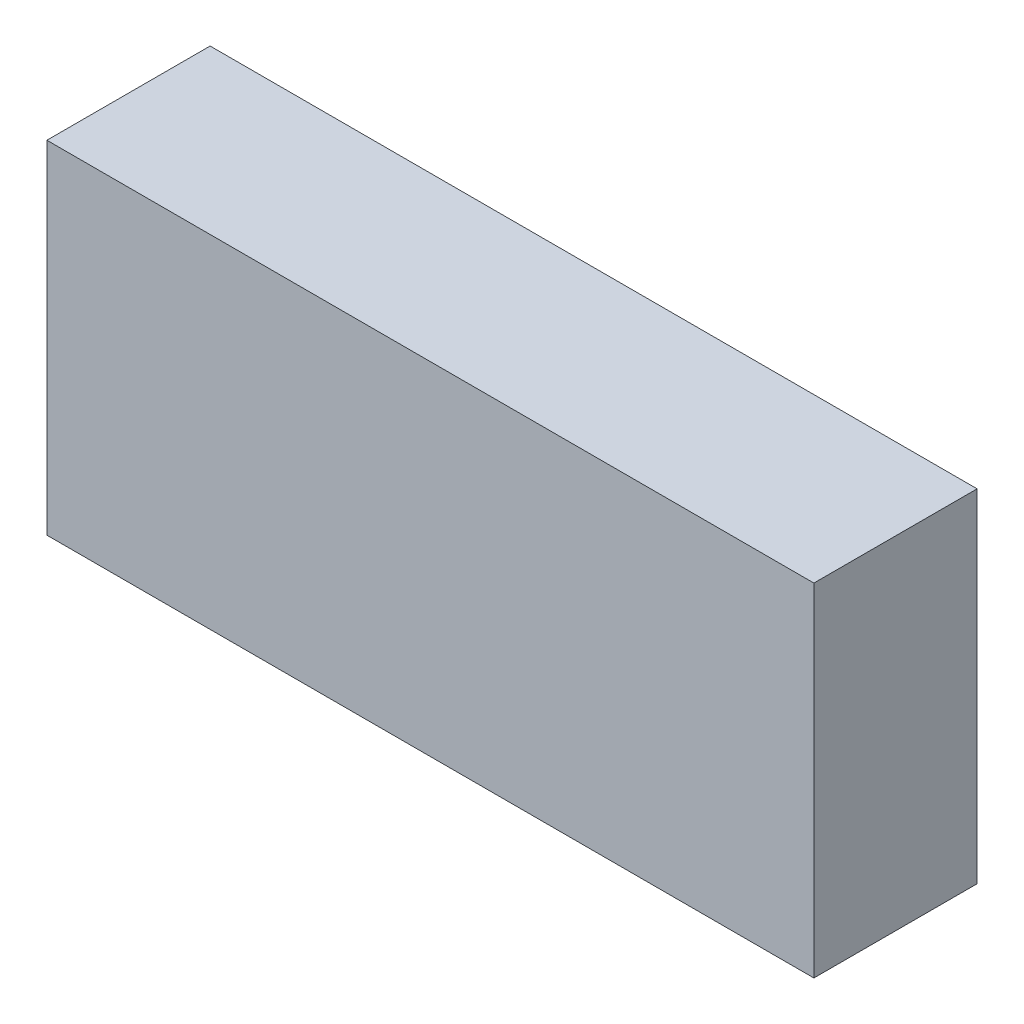
from build123d import *

# Parameters (mm, degrees)
SKETCH1_W               = 4.699
SKETCH1_H               = 2.0955
COMPONENT_OUTLINE_DEPTH = 1


with BuildPart() as part:
    # Sketch1 → Component_Outline (new body)
    with BuildSketch(Plane.XY):
        with Locations((0, 0.03175)):
            Rectangle(SKETCH1_W, SKETCH1_H)
    extrude(amount=COMPONENT_OUTLINE_DEPTH)


solid = part.part
